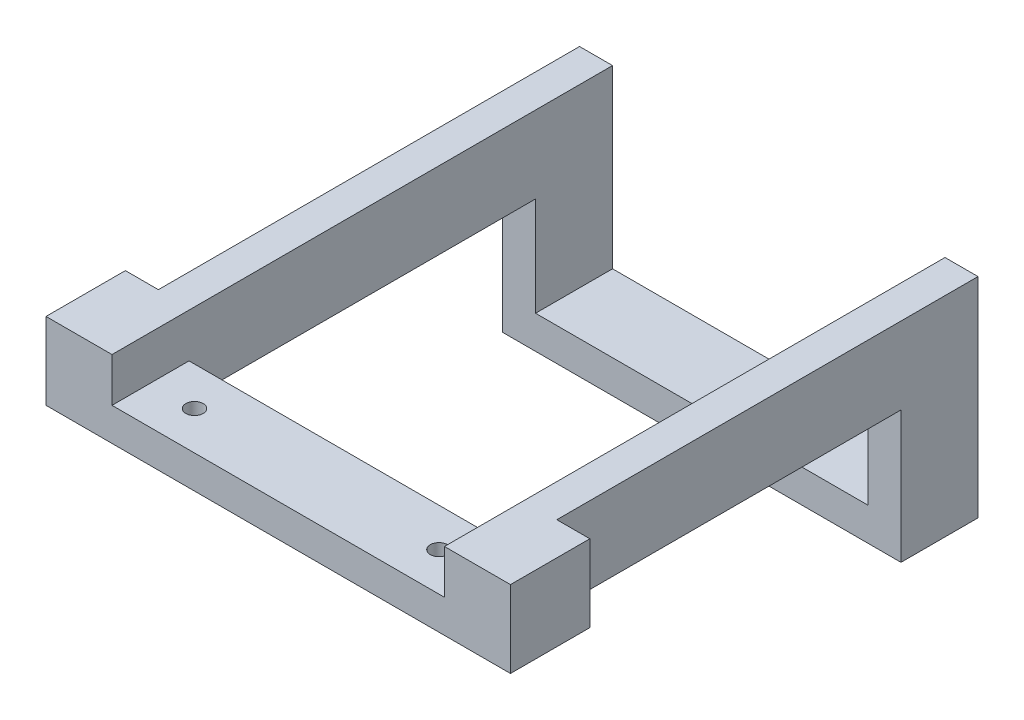
from build123d import *

# Parameters (mm, degrees)
SKETCH1_W                = 460
SKETCH1_H                = 88.9
BOSS_EXTRUDE1_DEPTH      = 38.1
SKETCH2_W                = 38.1
SKETCH2_H                = 88.9
BOSS_EXTRUDE2_DEPTH      = 910
SKETCH3_W                = 38.1
SKETCH3_H                = 88.9
BOSS_EXTRUDE3_DEPTH      = 577.85
SKETCH4_W                = 38.1
SKETCH4_H                = 91.631294093
BOSS_EXTRUDE4_DEPTH      = 615
BOSS_EXTRUDE4_DEPTH_BACK = 88.9
SKETCH5_W                = 91.631294093
SKETCH5_H                = 38.1
BOSS_EXTRUDE5_DEPTH      = 460
SKETCH7_W                = 460
SKETCH7_H                = 424.5
SKETCH7_W_2              = 38.1
SKETCH7_H_2              = 152.4
CUT_EXTRUDE1_DEPTH       = 577.85
SKETCH8_W                = 88.9
SKETCH8_H                = 38.1
BOSS_EXTRUDE6_DEPTH      = 383.8
SKETCH10_R               = 10
CUT_EXTRUDE2_DEPTH       = 38.1
SKETCH9_R                = 10
CUT_EXTRUDE3_DEPTH       = 38.1


with BuildPart() as part:
    # Sketch1 → Boss-Extrude1 (new body)
    with BuildSketch(Plane(origin=(0, 0, 0), x_dir=(1, 0, 0), z_dir=(0, 1, 0))):
        Rectangle(SKETCH1_W, SKETCH1_H)
    extrude(amount=BOSS_EXTRUDE1_DEPTH)

    # Sketch2 → Boss-Extrude2 (add)
    with BuildSketch(Plane(origin=(0, 38.1, 0), x_dir=(1, 0, 0), z_dir=(0, 1, 0))):
        with Locations((-210.95, 0)):
            Rectangle(SKETCH2_W, SKETCH2_H)
        with Locations((210.95, 0)):
            Rectangle(SKETCH2_W, SKETCH2_H)
    extrude(amount=BOSS_EXTRUDE2_DEPTH)

    # Sketch3 → Boss-Extrude3 (add)
    with BuildSketch(Plane(origin=(0, 0, -44.45), x_dir=(-1, 0, 0), z_dir=(0, 0, -1))):
        with Locations((210.95, 992.55)):
            Rectangle(SKETCH3_W, SKETCH3_H)
        with Locations((-210.95, 992.55)):
            Rectangle(SKETCH3_W, SKETCH3_H)
    extrude(amount=-BOSS_EXTRUDE3_DEPTH)

    # Sketch4 → Boss-Extrude4 (add, two sides)
    with BuildSketch(Plane.XZ.offset(-948.1)) as boss_extrude4_sk:
        with Locations((-249.05, 487.584352954)):
            Rectangle(SKETCH4_W, SKETCH4_H)
        with Locations((249.05, 487.584352954)):
            Rectangle(SKETCH4_W, SKETCH4_H)
    extrude(amount=BOSS_EXTRUDE4_DEPTH)
    extrude(boss_extrude4_sk.sketch, amount=-BOSS_EXTRUDE4_DEPTH_BACK)

    # Sketch5 → Boss-Extrude5 (add)
    with BuildSketch(Plane.ZY.offset(-230)):
        with Locations((487.584352954, 352.15)):
            Rectangle(SKETCH5_W, SKETCH5_H)
    extrude(amount=BOSS_EXTRUDE5_DEPTH)

    # Sketch7 → Cut-Extrude1 (cut)
    with BuildSketch(Plane.XY.offset(533.4)):
        with Locations((0, 583.45)):
            Rectangle(SKETCH7_W, SKETCH7_H)
        Polygon((268.1, -246.273106328), (268.1, 333.1), (-268.1, 333.1), (-268.1, 795.7), (-577.367310112, 795.7), (-577.367310112, -246.273106328), align=None)
        Polygon((268.1, 333.1), (268.1, 795.7), (230, 795.7), (230, 371.2), (-230, 371.2), (-230, 795.7), (-268.1, 795.7), (-268.1, 333.1), align=None)
        with Locations((249.05, 871.9)):
            Rectangle(SKETCH7_W_2, SKETCH7_H_2)
        with Locations((-249.05, 871.9)):
            Rectangle(SKETCH7_W_2, SKETCH7_H_2)
    extrude(amount=-CUT_EXTRUDE1_DEPTH, mode=Mode.SUBTRACT)

    # Sketch8 → Boss-Extrude6 (add)
    with BuildSketch(Plane(origin=(-191.9, 0, 0), x_dir=(0, 0, -1), z_dir=(1, 0, 0))):
        with Locations((0, 814.75)):
            Rectangle(SKETCH8_W, SKETCH8_H)
        with Locations((-488.95, 967.15)):
            Rectangle(SKETCH8_W, SKETCH8_H)
    extrude(amount=BOSS_EXTRUDE6_DEPTH)

    # Sketch10 → Cut-Extrude2 (cut)
    with BuildSketch(Plane.XZ.offset(-948.1)):
        with Locations((-141.1, 488.95)):
            Circle(SKETCH10_R)
        with Locations((141.1, 488.95)):
            Circle(SKETCH10_R)
    extrude(amount=-CUT_EXTRUDE2_DEPTH, mode=Mode.SUBTRACT)

    # Sketch9 → Cut-Extrude3 (cut)
    with BuildSketch(Plane.XZ.offset(-795.7)):
        Circle(SKETCH9_R)
    extrude(amount=-CUT_EXTRUDE3_DEPTH, mode=Mode.SUBTRACT)


solid = part.part
